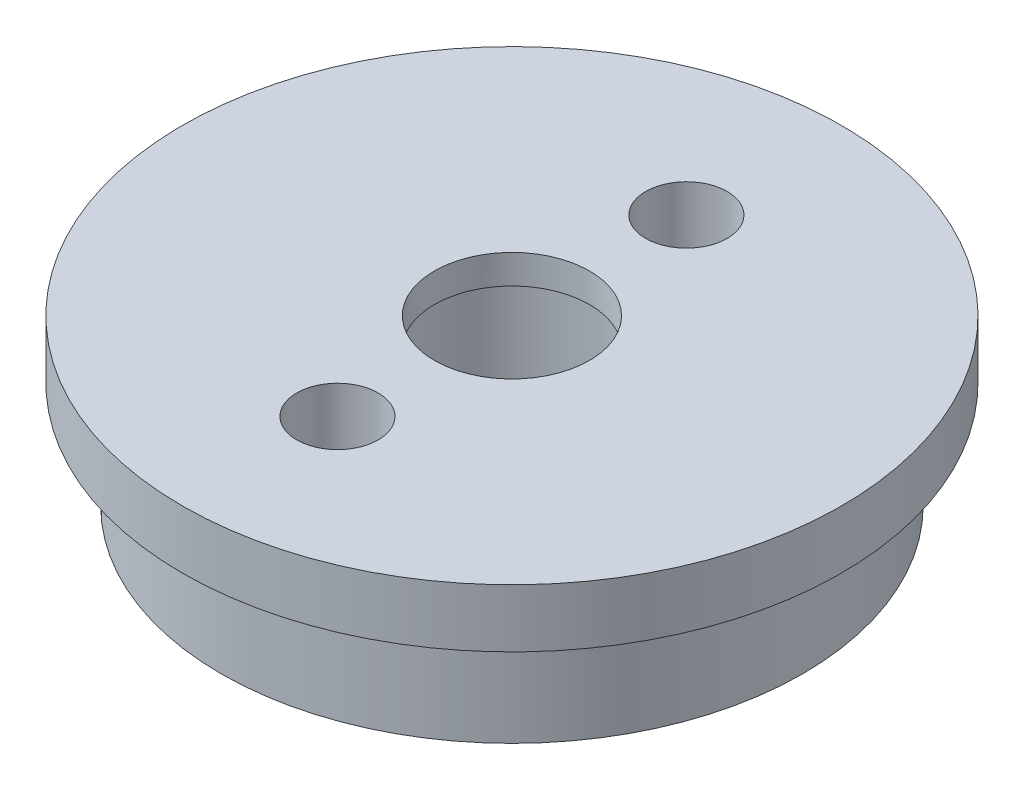
from build123d import *

# Parameters (mm, degrees)
SKETCH1_R           = 15
BOSS_EXTRUDE1_DEPTH = 5.5
SKETCH2_R           = 17
BOSS_EXTRUDE2_DEPTH = 3
SKETCH3_R           = 5.1
CUT_EXTRUDE1_DEPTH  = 7
SKETCH4_R           = 2.1
SKETCH4_R_2         = 4
CUT_EXTRUDE2_DEPTH  = 6


with BuildPart() as part:
    # Sketch1 → Boss-Extrude1 (new body)
    with BuildSketch(Plane(origin=(0, 0, 0), x_dir=(1, 0, 0), z_dir=(0, 1, 0))):
        Circle(SKETCH1_R)
    extrude(amount=BOSS_EXTRUDE1_DEPTH)

    # Sketch2 → Boss-Extrude2 (add)
    with BuildSketch(Plane(origin=(0, 5.5, 0), x_dir=(1, 0, 0), z_dir=(0, 1, 0))):
        Circle(SKETCH2_R)
    extrude(amount=BOSS_EXTRUDE2_DEPTH)

    # Sketch3 → Cut-Extrude1 (cut)
    with BuildSketch(Plane.XZ):
        Circle(SKETCH3_R)
    extrude(amount=-CUT_EXTRUDE1_DEPTH, mode=Mode.SUBTRACT)

    # Sketch4 → Cut-Extrude2 (cut)
    with BuildSketch(Plane(origin=(0, 8.5, 0), x_dir=(1, 0, 0), z_dir=(0, 1, 0))):
        with Locations((0, 9)):
            Circle(SKETCH4_R)
        with Locations((0, -9)):
            Circle(SKETCH4_R)
        Circle(SKETCH4_R_2)
    extrude(amount=-CUT_EXTRUDE2_DEPTH, mode=Mode.SUBTRACT)


solid = part.part
